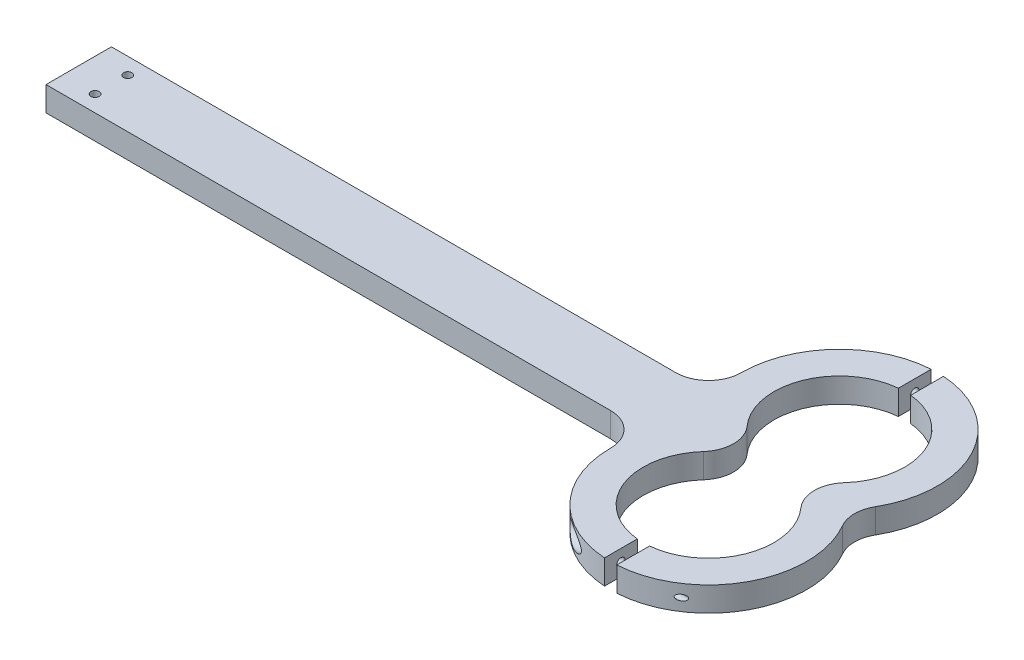
from build123d import *

# Parameters (mm, degrees)
BOSS_EXTRUDE1_DEPTH   = 4.7625
F_4_CLEARANCE_HOLE1_D = 3.2639
CUT_EXTRUDE1_DEPTH    = 10.525
CUT_EXTRUDE2_START    = 7.9375
SKETCH26_R            = 3.81
CUT_EXTRUDE2_DEPTH    = 263.239436686
F_4_40_TAPPED_HOLE1_D = 2.2606


with BuildPart() as part:
    # Sketch2 → Boss-Extrude1 (new body, symmetric)
    with BuildSketch(Plane(origin=(0, 0, 0), x_dir=(1, 0, 0), z_dir=(0, 1, 0))):
        with BuildLine():
            Line((0, 12.7), (219.2, 12.7))
            ThreePointArc((219.2, 12.7), (228.180256121, 16.419743879), (231.9, 25.4))
            ThreePointArc((231.9, 25.4), (279.861005618, 62.201773982), (302.995567884, 6.35))
            ThreePointArc((302.995567884, 6.35), (301.294090512, 0), (302.995567884, -6.35))
            ThreePointArc((302.995567884, -6.35), (279.861005618, -62.201773982), (231.9, -25.4))
            ThreePointArc((231.9, -25.4), (228.180256121, -16.419743879), (219.2, -12.7))
            Line((219.2, -12.7), (0, -12.7))
            Line((0, -12.7), (0, 12.7))
        make_face()
        with BuildLine():
            ThreePointArc((288.932042209, 8.466666667), (270, 50.8), (251.067957791, 8.466666667))
            ThreePointArc((251.067957791, 8.466666667), (254.301936686, 0), (251.067957791, -8.466666667))
            ThreePointArc((251.067957791, -8.466666667), (270, -50.8), (288.932042209, -8.466666667))
            ThreePointArc((288.932042209, -8.466666667), (285.698063314, 0), (288.932042209, 8.466666667))
        make_face(mode=Mode.SUBTRACT)
    extrude(amount=BOSS_EXTRUDE1_DEPTH, both=True)

    # #4 Clearance Hole1 (through all)
    with Locations(Plane(origin=(0, -4.7625, 0), x_dir=(-1, 0, 0), z_dir=(0, -1, 0))):
        with Locations((-12.7, -6.35), (-12.7, 6.35)):
            Hole(F_4_CLEARANCE_HOLE1_D / 2)

    # Sketch14 → Cut-Extrude1 (cut, through all)
    with BuildSketch(Plane.XZ.offset(4.7625)):
        with BuildLine():
            Line((267.61875, -50.688132561), (267.61875, -63.425513125))
            ThreePointArc((267.61875, -63.425513125), (270, -63.5), (272.38125, -63.425513125))
            Line((272.38125, -63.425513125), (272.38125, -50.688132561))
            ThreePointArc((272.38125, -50.688132561), (270, -50.8), (267.61875, -50.688132561))
        make_face()
        with BuildLine():
            Line((267.61875, 50.688132561), (267.61875, 63.425513125))
            ThreePointArc((267.61875, 63.425513125), (270, 63.5), (272.38125, 63.425513125))
            Line((272.38125, 63.425513125), (272.38125, 50.688132561))
            ThreePointArc((272.38125, 50.688132561), (270, 50.8), (267.61875, 50.688132561))
        make_face()
    extrude(amount=-CUT_EXTRUDE1_DEPTH, mode=Mode.SUBTRACT)

    # Sketch21 → #4 Clearance Hole2 (revolve, cut)
    with BuildSketch(Plane(origin=(254.301936686, 0, 57.056822843), x_dir=(0, 0, 1), z_dir=(0, 1, 0))):
        Polygon((0, 0), (0, 18.078313314), (1.63195, 17.097738827), (1.63195, 0), align=None)
    f_4_clearance_hole2 = revolve(axis=Axis((247.951936686, 0, 57.056822843), (1, 0, 0)), mode=Mode.SUBTRACT)

    # Sketch26 → Cut-Extrude2 (cut, through all)
    with BuildSketch(Plane(origin=(254.301936686, 0, 0), x_dir=(0, 0, -1), z_dir=(1, 0, 0)).offset(CUT_EXTRUDE2_START)):
        with Locations((-57.056822843, 0)):
            Circle(SKETCH26_R)
    cut_extrude2 = extrude(amount=-CUT_EXTRUDE2_DEPTH, mode=Mode.SUBTRACT)

    # #4-40 Tapped Hole1 (through all)
    with Locations(Plane.ZY.offset(-272.38125)):
        with Locations((57.056822843, 0)):
            f_4_40_tapped_hole1 = Hole(F_4_40_TAPPED_HOLE1_D / 2)

    # Mirror1: #4 Clearance Hole2, Cut-Extrude2, #4-40 Tapped Hole1 across plane
    add(f_4_clearance_hole2.mirror(Plane.XY), mode=Mode.SUBTRACT)
    add(cut_extrude2.mirror(Plane.XY), mode=Mode.SUBTRACT)
    add(f_4_40_tapped_hole1.mirror(Plane.XY), mode=Mode.SUBTRACT)


solid = part.part
